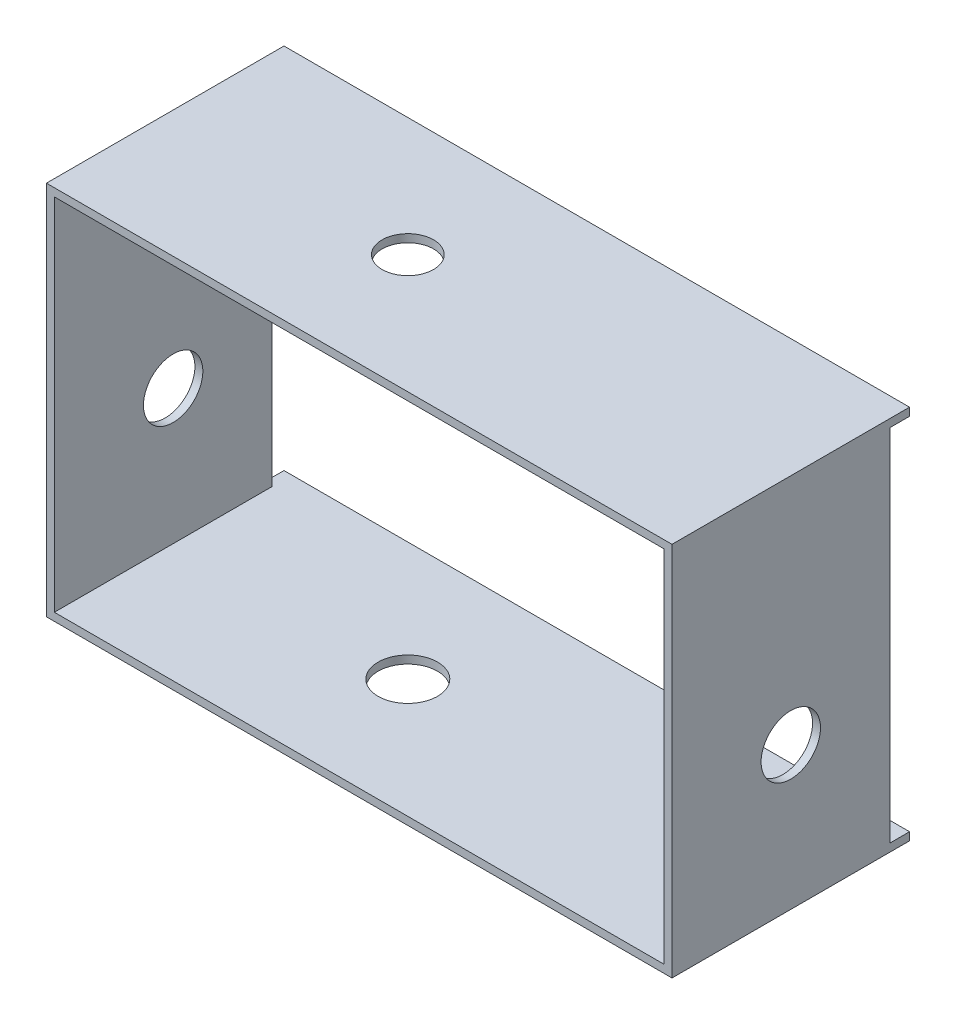
from build123d import *

# Parameters (mm, degrees)
SKETCH4_W           = 195.58
SKETCH4_H           = 76.2
SKETCH4_R           = 8.255
BOSS_EXTRUDE2_DEPTH = 2.54
SKETCH7_R           = 9.525
SKETCH7_W           = 76.2
SKETCH7_H           = 2.54
BOSS_EXTRUDE4_DEPTH = 2.54
SKETCH9_R           = 9.525
BOSS_EXTRUDE5_DEPTH = 2.54
SKETCH10_R          = 9.525
BOSS_EXTRUDE6_DEPTH = 2.54


with BuildPart() as part:
    # Sketch4 → Boss-Extrude2 (new body)
    with BuildSketch(Plane(origin=(0, 0, 0), x_dir=(1, 0, 0), z_dir=(0, 1, 0))):
        with Locations((97.79, 38.1)):
            Rectangle(SKETCH4_W, SKETCH4_H)
        with Locations((75.2856, 38.1)):
            Circle(SKETCH4_R, mode=Mode.SUBTRACT)
    extrude(amount=BOSS_EXTRUDE2_DEPTH)

    # Sketch7 → Boss-Extrude4 (add)
    with BuildSketch(Plane(origin=(195.58, 0, 0), x_dir=(0, 0, -1), z_dir=(1, 0, 0))):
        Polygon((69.85, 0), (0, 0), (0, -115.396245002), (0, -117.936245002), (76.2, -117.936245002), (76.2, -115.396245002), (69.85, -115.396245002), align=None)
        with Locations((38.1, -72.216245002)):
            Circle(SKETCH7_R, mode=Mode.SUBTRACT)
        with Locations((38.1, 1.27)):
            Rectangle(SKETCH7_W, SKETCH7_H)
    extrude(amount=BOSS_EXTRUDE4_DEPTH)

    # Sketch9 → Boss-Extrude5 (add)
    with BuildSketch(Plane(origin=(0, -117.936245002, 0), x_dir=(-1, 0, 0), z_dir=(0, -1, 0))):
        Polygon((-198.12, 0), (-195.58, 0), (0, 0), (0, 76.2), (-195.58, 76.2), (-198.12, 76.2), align=None)
        with Locations((-75.2856, 38.1)):
            Circle(SKETCH9_R, mode=Mode.SUBTRACT)
    extrude(amount=-BOSS_EXTRUDE5_DEPTH)

    # Sketch10 → Boss-Extrude6 (add)
    with BuildSketch(Plane.ZY):
        Polygon((0, 2.54), (0, 0), (0, -115.396245002), (0, -117.936245002), (-76.2, -117.936245002), (-76.2, -115.396245002), (-69.85, -115.396245002), (-69.85, 0), (-76.2, 0), (-76.2, 2.54), align=None)
        with Locations((-38.1, -72.216245002)):
            Circle(SKETCH10_R, mode=Mode.SUBTRACT)
    extrude(amount=BOSS_EXTRUDE6_DEPTH)


solid = part.part
